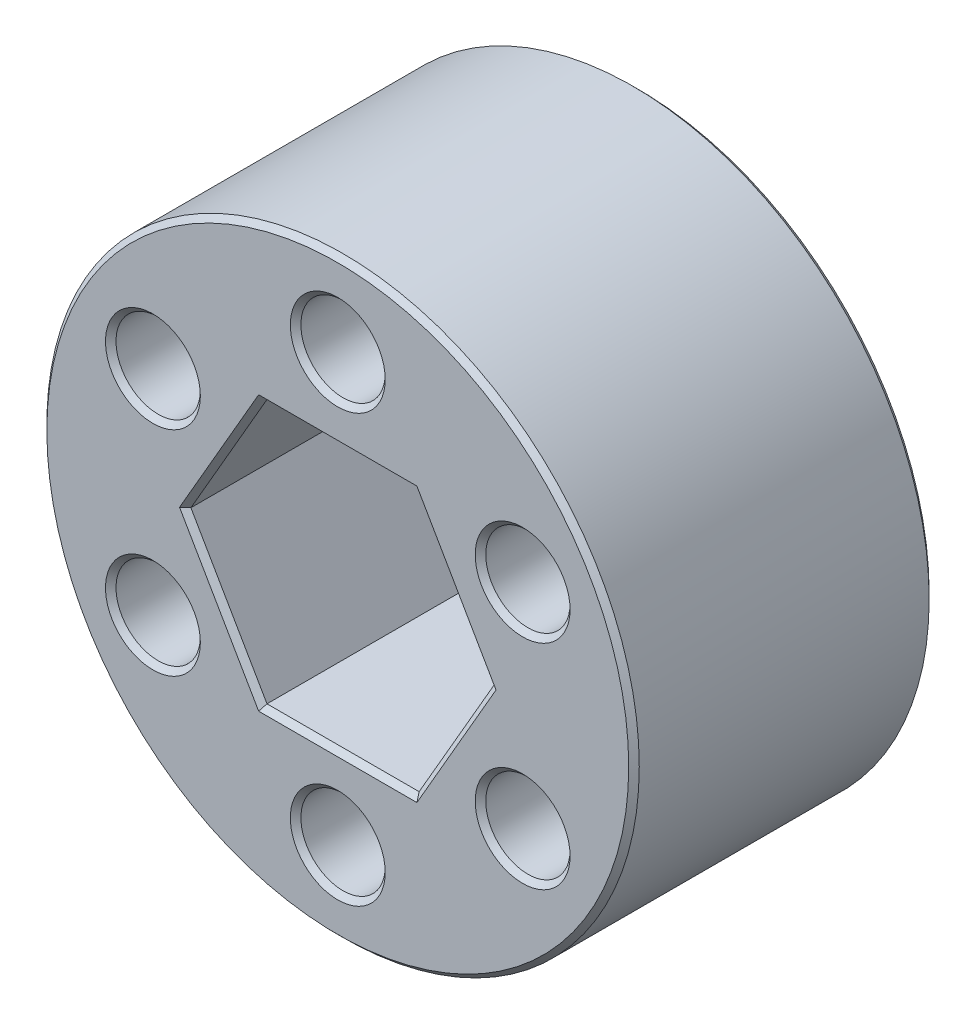
from build123d import *

# Parameters (mm, degrees)
SKETCH1_R           = 14.2748
SKETCH1_R_2         = 2.032
BOSS_EXTRUDE1_DEPTH = 14.478
CHAMFER1_SIZE       = 0.254


with BuildPart() as part:
    # Sketch1 → Boss-Extrude1 (new body)
    with BuildSketch(Plane.XY):
        Circle(SKETCH1_R)
        with Locations((0, 10.287)):
            Circle(SKETCH1_R_2, mode=Mode.SUBTRACT)
        with Locations((8.908803329, 5.1435)):
            Circle(SKETCH1_R_2, mode=Mode.SUBTRACT)
        with Locations((8.908803329, -5.1435)):
            Circle(SKETCH1_R_2, mode=Mode.SUBTRACT)
        with Locations((0, -10.287)):
            Circle(SKETCH1_R_2, mode=Mode.SUBTRACT)
        with Locations((-8.908803329, -5.1435)):
            Circle(SKETCH1_R_2, mode=Mode.SUBTRACT)
        with Locations((-8.908803329, 5.1435)):
            Circle(SKETCH1_R_2, mode=Mode.SUBTRACT)
        Polygon((-7.332348419, 0), (-3.666174209, -6.35), (3.666174209, -6.35), (7.332348419, 0), (3.666174209, 6.35), (-3.666174209, 6.35), align=None, mode=Mode.SUBTRACT)
    extrude(amount=BOSS_EXTRUDE1_DEPTH)

    # Chamfer1
    chamfer1_edges = [part.edges().sort_by_distance(p)[0] for p in [
        (0, -6.35, 0),
        (5.499261314, -3.175, 0),
        (5.499261314, 3.175, 0),
        (0, 6.35, 0),
        (-5.499261314, 3.175, 14.478),
        (-5.499261314, -3.175, 14.478),
        (0, -6.35, 14.478),
        (5.499261314, -3.175, 14.478),
        (5.499261314, 3.175, 14.478),
        (0, 6.35, 14.478),
        (-14.2748, 0, 0),
        (-2.032, 10.287, 0),
        (-2.032, 10.287, 14.478),
        (6.876803329, 5.1435, 0),
        (6.876803329, 5.1435, 14.478),
        (6.876803329, -5.1435, 0),
        (6.876803329, -5.1435, 14.478),
        (-2.032, -10.287, 0),
        (-2.032, -10.287, 14.478),
        (-10.940803329, -5.1435, 0),
        (-10.940803329, -5.1435, 14.478),
        (-14.2748, 0, 14.478),
        (-10.940803329, 5.1435, 0),
        (-10.940803329, 5.1435, 14.478),
        (-5.499261314, 3.175, 0),
        (-5.499261314, -3.175, 0),
    ]]
    chamfer(chamfer1_edges, length=CHAMFER1_SIZE)


solid = part.part
